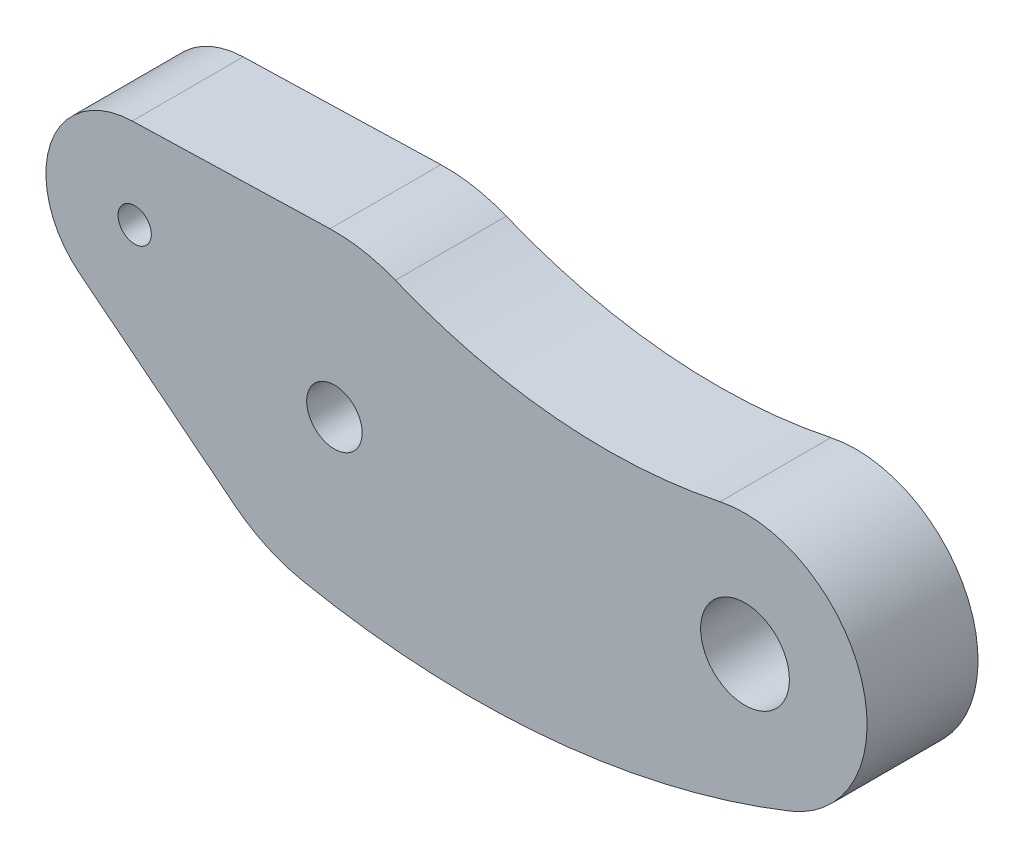
from build123d import *

# Parameters (mm, degrees)
SKETCH1_R           = 1.25
SKETCH1_R_2         = 2
SKETCH1_R_3         = 0.75
BOSS_EXTRUDE1_DEPTH = 5


with BuildPart() as part:
    # Sketch1 → Boss-Extrude1 (new body)
    with BuildSketch(Plane.XY):
        with BuildLine():
            Line((-11.488369565, -0.131775361), (-4.510169836, -5.676342841))
            ThreePointArc((-4.510169836, -5.676342841), (-3.050109649, -6.577182613), (-1.419255622, -7.109726681))
            ThreePointArc((-1.419255622, -7.109726681), (9.701935293, -7.700842906), (20.533350493, -5.110331278))
            ThreePointArc((20.533350493, -5.110331278), (23.765864573, 1.587661896), (17.36972181, 5.382608217))
            ThreePointArc((17.36972181, 5.382608217), (9.957149012, 4.950641907), (2.743644121, 6.710805983))
            ThreePointArc((2.743644121, 6.710805983), (1.298650223, 7.132741941), (-0.202330164, 7.247176175))
            Line((-0.202330164, 7.247176175), (-9.111630435, 6.998442027))
            ThreePointArc((-9.111630435, 6.998442027), (-12.794733192, 4.264911064), (-11.488369565, -0.131775361))
        make_face()
        Circle(SKETCH1_R, mode=Mode.SUBTRACT)
        with Locations((18.5, 0)):
            Circle(SKETCH1_R_2, mode=Mode.SUBTRACT)
        with Locations((-9, 3)):
            Circle(SKETCH1_R_3, mode=Mode.SUBTRACT)
    extrude(amount=BOSS_EXTRUDE1_DEPTH)


solid = part.part
